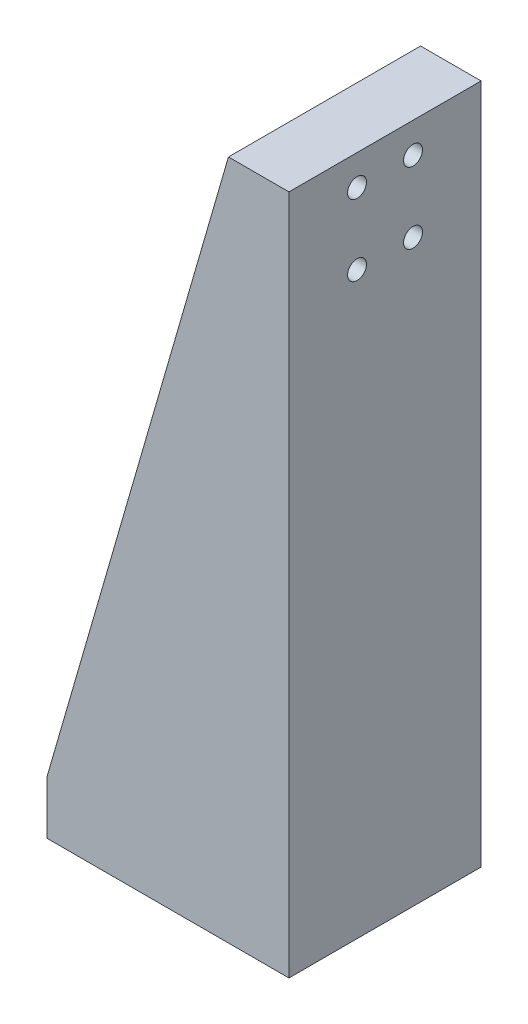
from build123d import *

# Parameters (mm, degrees)
BOSS_EXTRUDE1_DEPTH = 25.4
RIB1_REACH          = 100.839
SKETCH4_WALL_W      = 286.07835369
SKETCH4_WALL_H      = 5
CUT_EXTRUDE2_REACH  = 94.51
SKETCH5_R           = 1.55
M3_TAPPED_HOLE2_D   = 2.5


with BuildPart() as part:
    # Sketch1 → Boss-Extrude1 (new body)
    with BuildSketch(Plane.XY):
        Polygon((0, 0), (0, 7), (24, 7), (24, 90), (32, 90), (32, 0), align=None)
    extrude(amount=BOSS_EXTRUDE1_DEPTH)

    # Sketch4 wall → Rib1 (add, up to next)
    with BuildSketch(Plane(origin=(12, 48.5, 25.4), x_dir=(-0.277777033563, -0.960645574406, 0), z_dir=(0.960645574406, -0.277777033563, 0)), mode=Mode.PRIVATE) as rib1_sk1:
        with Locations((0, 2.5)):
            Rectangle(SKETCH4_WALL_W, SKETCH4_WALL_H)
    rib1_tool1 = extrude(rib1_sk1.sketch, amount=RIB1_REACH, mode=Mode.PRIVATE) - part.part
    rib1 = rib1_tool1.solids().sort_by_distance((12, 48.5, 25.4))[0]
    add(rib1)

    # Mirror1: Rib1 across plane
    add(rib1.mirror(Plane.XY.offset(12.7)))

    # Sketch5 → Cut-Extrude2 (cut, up to next)
    with BuildSketch(Plane(origin=(0, 7, 0), x_dir=(1, 0, 0), z_dir=(0, 1, 0)), mode=Mode.PRIVATE) as cut_extrude2_sk1:
        with Locations(Location((4, -9, 0), (0, 0, 270))):
            Circle(SKETCH5_R)
    cut_extrude2_tool1 = extrude(cut_extrude2_sk1.sketch, amount=-CUT_EXTRUDE2_REACH, mode=Mode.PRIVATE) & part.part
    # Sketch5 → Cut-Extrude2 (cut, up to next)
    with BuildSketch(Plane(origin=(0, 7, 0), x_dir=(1, 0, 0), z_dir=(0, 1, 0)), mode=Mode.PRIVATE) as cut_extrude2_sk2:
        with Locations(Location((20, -9, 0), (0, 0, 270))):
            Circle(SKETCH5_R)
    cut_extrude2_tool2 = extrude(cut_extrude2_sk2.sketch, amount=-CUT_EXTRUDE2_REACH, mode=Mode.PRIVATE) & part.part
    # Sketch5 → Cut-Extrude2 (cut, up to next)
    with BuildSketch(Plane(origin=(0, 7, 0), x_dir=(1, 0, 0), z_dir=(0, 1, 0)), mode=Mode.PRIVATE) as cut_extrude2_sk3:
        with Locations(Location((20, -16.4, 0), (0, 0, 270))):
            Circle(SKETCH5_R)
    cut_extrude2_tool3 = extrude(cut_extrude2_sk3.sketch, amount=-CUT_EXTRUDE2_REACH, mode=Mode.PRIVATE) & part.part
    # Sketch5 → Cut-Extrude2 (cut, up to next)
    with BuildSketch(Plane(origin=(0, 7, 0), x_dir=(1, 0, 0), z_dir=(0, 1, 0)), mode=Mode.PRIVATE) as cut_extrude2_sk4:
        with Locations(Location((4, -16.4, 0), (0, 0, 270))):
            Circle(SKETCH5_R)
    cut_extrude2_tool4 = extrude(cut_extrude2_sk4.sketch, amount=-CUT_EXTRUDE2_REACH, mode=Mode.PRIVATE) & part.part
    add(cut_extrude2_tool1.solids().sort_by_distance((4, 7, 9))[0], mode=Mode.SUBTRACT)
    add(cut_extrude2_tool2.solids().sort_by_distance((20, 7, 9))[0], mode=Mode.SUBTRACT)
    add(cut_extrude2_tool3.solids().sort_by_distance((20, 7, 16.4))[0], mode=Mode.SUBTRACT)
    add(cut_extrude2_tool4.solids().sort_by_distance((4, 7, 16.4))[0], mode=Mode.SUBTRACT)

    # M3 Tapped Hole2 (through all)
    with Locations(Plane(origin=(32, 0, 0), x_dir=(0, 0, -1), z_dir=(1, 0, 0))):
        with Locations((-9, 86), (-16.4, 76.6), (-16.4, 86), (-9, 76.6)):
            Hole(M3_TAPPED_HOLE2_D / 2)


solid = part.part
